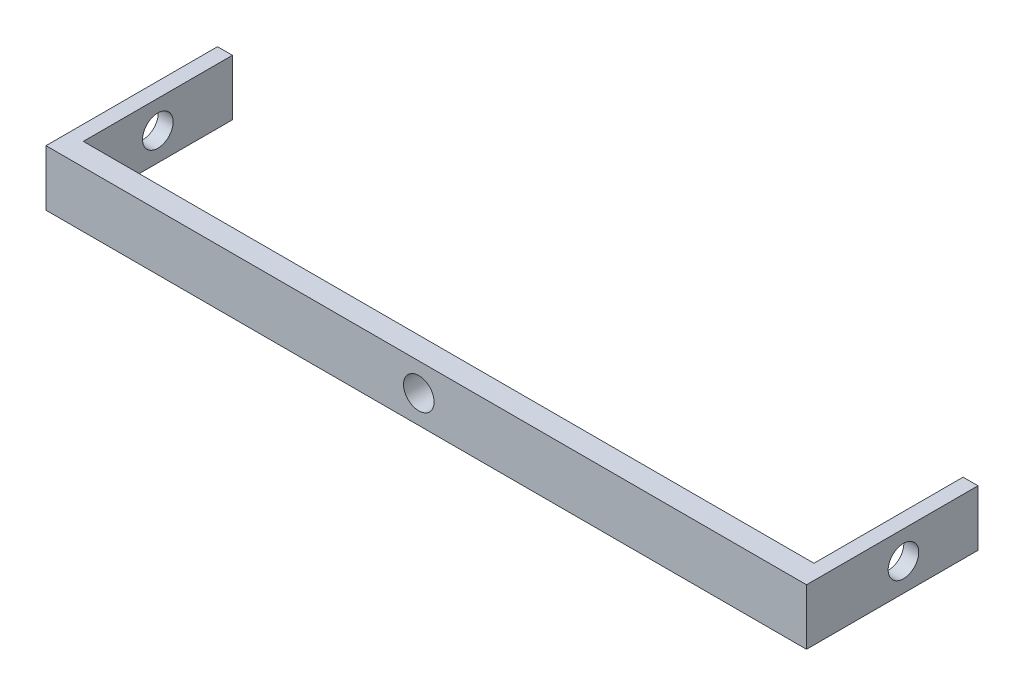
from build123d import *

# Parameters (mm, degrees)
SKETCH1_W           = 100
SKETCH1_H           = 7.5
BOSS_EXTRUDE1_DEPTH = 3
BOSS_EXTRUDE2_START = 50
SKETCH2_W           = 23
SKETCH2_H           = 7.5
BOSS_EXTRUDE2_DEPTH = 2
BOSS_EXTRUDE3_START = -50
SKETCH2_2_W         = 23
SKETCH2_2_H         = 7.5
BOSS_EXTRUDE3_DEPTH = 2
CUT_EXTRUDE1_START  = -50
SKETCH3_R           = 2.05
CUT_EXTRUDE1_DEPTH  = 103
CUT_EXTRUDE2_START  = 3
SKETCH4_R           = 2.05
CUT_EXTRUDE2_DEPTH  = 24


with BuildPart() as part:
    # Sketch1 → Boss-Extrude1 (new body)
    with BuildSketch(Plane.XY):
        Rectangle(SKETCH1_W, SKETCH1_H)
    extrude(amount=BOSS_EXTRUDE1_DEPTH)

    # Sketch2 → Boss-Extrude2 (add)
    with BuildSketch(Plane(origin=(0, 0, 0), x_dir=(0, 0, -1), z_dir=(1, 0, 0)).offset(BOSS_EXTRUDE2_START)):
        with Locations((8.5, 0)):
            Rectangle(SKETCH2_W, SKETCH2_H)
    extrude(amount=BOSS_EXTRUDE2_DEPTH)

    # Sketch2_2 → Boss-Extrude3 (add)
    with BuildSketch(Plane(origin=(0, 0, 0), x_dir=(0, 0, -1), z_dir=(1, 0, 0)).offset(BOSS_EXTRUDE3_START)):
        with Locations((8.5, 0)):
            Rectangle(SKETCH2_2_W, SKETCH2_2_H)
    extrude(amount=BOSS_EXTRUDE3_DEPTH)

    # Sketch3 → Cut-Extrude1 (cut, through all)
    with BuildSketch(Plane(origin=(0, 0, 0), x_dir=(0, 0, -1), z_dir=(1, 0, 0)).offset(CUT_EXTRUDE1_START)):
        with Locations((10, 0)):
            Circle(SKETCH3_R)
    extrude(amount=CUT_EXTRUDE1_DEPTH, mode=Mode.SUBTRACT)

    # Sketch4 → Cut-Extrude2 (cut, through all)
    with BuildSketch(Plane.XY.offset(CUT_EXTRUDE2_START)):
        Circle(SKETCH4_R)
    extrude(amount=-CUT_EXTRUDE2_DEPTH, mode=Mode.SUBTRACT)


solid = part.part
